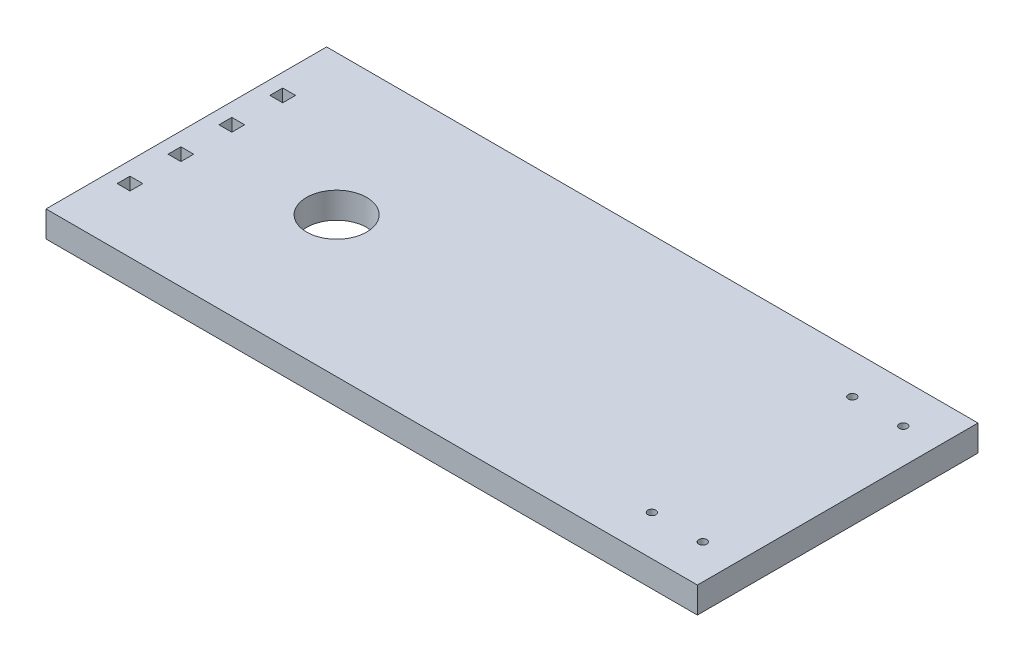
from build123d import *

# Parameters (mm, degrees)
SKETCH1_W           = 32.5
SKETCH1_H           = 14
BOSS_EXTRUDE1_DEPTH = 1.3
SKETCH2_R           = 0.2
SKETCH2_W           = 0.64
SKETCH2_H           = 0.64
CUT_EXTRUDE1_DEPTH  = 2.3
SKETCH3_R           = 1.5
CUT_EXTRUDE2_DEPTH  = 10


with BuildPart() as part:
    # Sketch1 → Boss-Extrude1 (new body)
    with BuildSketch(Plane(origin=(0, 0, 0), x_dir=(1, 0, 0), z_dir=(0, 1, 0))):
        Rectangle(SKETCH1_W, SKETCH1_H)
    extrude(amount=BOSS_EXTRUDE1_DEPTH)

    # Sketch2 → Cut-Extrude1 (cut, through all)
    with BuildSketch(Plane(origin=(0, 1.3, 0), x_dir=(1, 0, 0), z_dir=(0, 1, 0))):
        with Locations((14.52, -5)):
            Circle(SKETCH2_R)
        with Locations((11.98, -5)):
            Circle(SKETCH2_R)
        with Locations((11.98, 5)):
            Circle(SKETCH2_R)
        with Locations((14.52, 5)):
            Circle(SKETCH2_R)
        with Locations((-15.25, 3.81)):
            Rectangle(SKETCH2_W, SKETCH2_H)
        with Locations((-15.25, 1.27)):
            Rectangle(SKETCH2_W, SKETCH2_H)
        with Locations((-15.25, -1.27)):
            Rectangle(SKETCH2_W, SKETCH2_H)
        with Locations((-15.25, -3.81)):
            Rectangle(SKETCH2_W, SKETCH2_H)
    extrude(amount=-CUT_EXTRUDE1_DEPTH, mode=Mode.SUBTRACT)

    # Sketch3 → Cut-Extrude2 (cut)
    with BuildSketch(Plane(origin=(0, 1.3, 0), x_dir=(1, 0, 0), z_dir=(0, 1, 0))):
        with Locations((-8.75, 0)):
            Circle(SKETCH3_R)
    extrude(amount=-CUT_EXTRUDE2_DEPTH, mode=Mode.SUBTRACT)


solid = part.part
